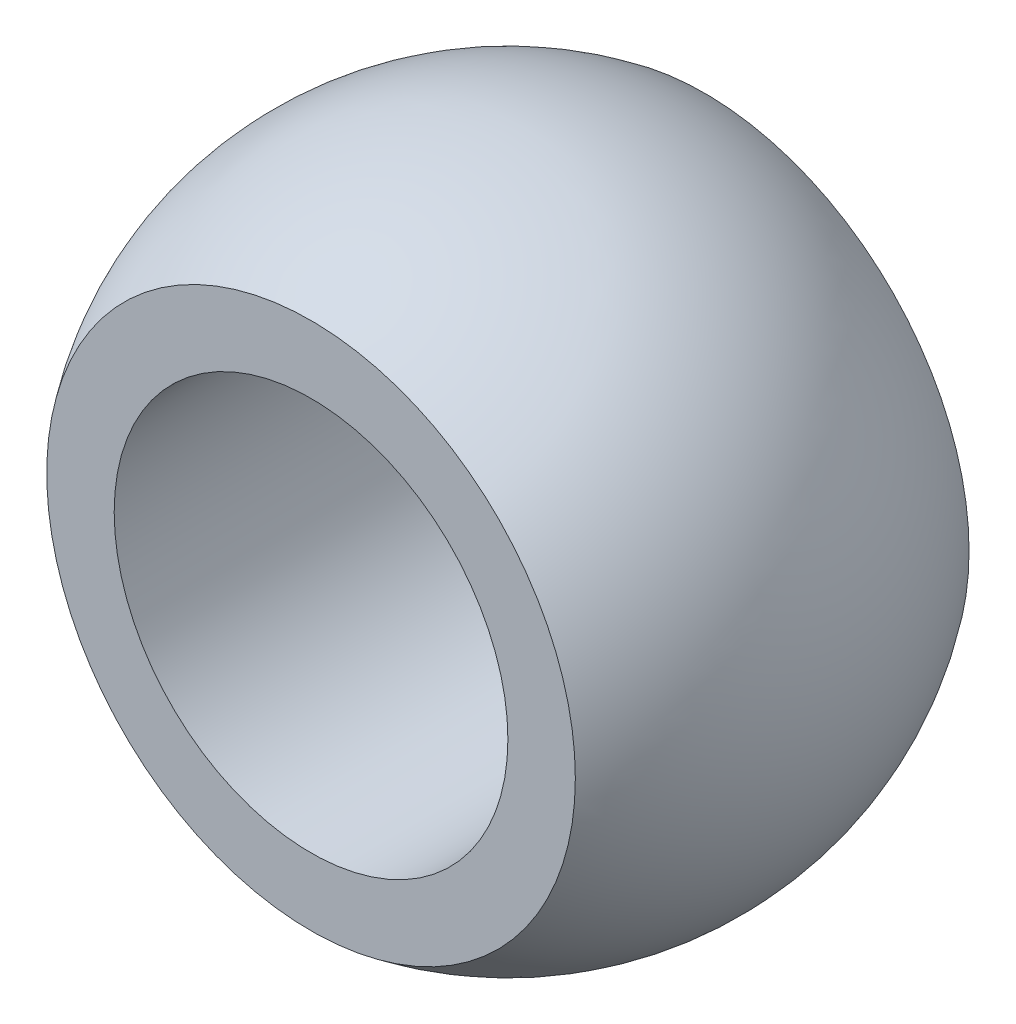
from build123d import *

# Parameters (mm, degrees)
SKETCH4_R           = 1.4224
EXTRUDE1_DEPTH      = 3.38125
EXTRUDE1_DEPTH_BACK = 3.38125
SKETCH5_OUTSIDE_W   = 8.412
SKETCH5_OUTSIDE_H   = 8.412
SKETCH5_OUTSIDE_R   = 1.4224
EXTRUDE2_DEPTH      = 2.54
SKETCH6_OUTSIDE_W   = 8.412
SKETCH6_OUTSIDE_H   = 8.412
SKETCH6_OUTSIDE_R   = 1.4224
EXTRUDE3_DEPTH      = 2.54


with BuildPart() as part:
    # Sketch2 → Revolve2 (revolve)
    with BuildSketch(Plane.XY):
        with BuildLine():
            Line((0, 2.38125), (0, -2.38125))
            ThreePointArc((0, -2.38125), (2.38125, 0), (0, 2.38125))
        make_face()
    revolve(axis=Axis((0, 2.38125, 0), (0, -1, 0)))

    # Sketch4 → Extrude1 (cut, two sides)
    with BuildSketch(Plane.XY) as extrude1_sk:
        Circle(SKETCH4_R)
    extrude(amount=EXTRUDE1_DEPTH, mode=Mode.SUBTRACT)
    extrude(extrude1_sk.sketch, amount=-EXTRUDE1_DEPTH_BACK, mode=Mode.SUBTRACT)

    # Sketch5 outside → Extrude2 (cut)
    with BuildSketch(Plane.XY.offset(-1.4224)):
        Rectangle(SKETCH5_OUTSIDE_W, SKETCH5_OUTSIDE_H)
        Circle(SKETCH5_OUTSIDE_R, mode=Mode.SUBTRACT)
    extrude(amount=-EXTRUDE2_DEPTH, mode=Mode.SUBTRACT)

    # Sketch6 outside → Extrude3 (cut)
    with BuildSketch(Plane.XY.offset(1.4224)):
        Rectangle(SKETCH6_OUTSIDE_W, SKETCH6_OUTSIDE_H)
        Circle(SKETCH6_OUTSIDE_R, mode=Mode.SUBTRACT)
    extrude(amount=EXTRUDE3_DEPTH, mode=Mode.SUBTRACT)


solid = part.part
